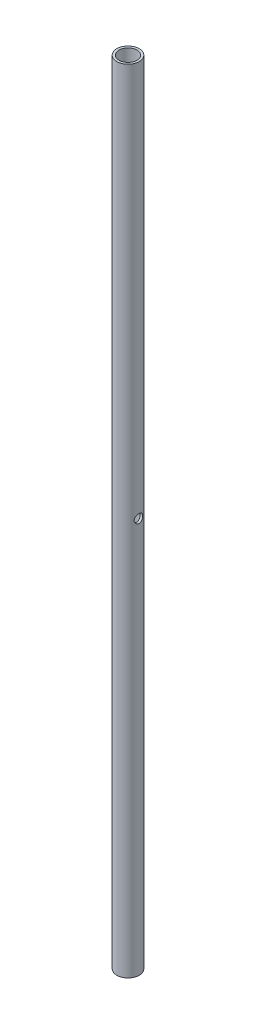
from build123d import *

# Parameters (mm, degrees)
SKETCH1_R               = 16.7005
SKETCH1_R_2             = 13.335
BOSS_EXTRUDE1_DEPTH     = 520.7
SKETCH3_R               = 16.7005
SKETCH3_R_2             = 13.335
BOSS_EXTRUDE2_DEPTH     = 660.4
SKETCH2_R               = 6.35
CUT_EXTRUDE1_DEPTH      = 17.7005
CUT_EXTRUDE1_DEPTH_BACK = 17.7005


with BuildPart() as part:
    # Sketch1 → Boss-Extrude1 (new body)
    with BuildSketch(Plane(origin=(0, 0, 0), x_dir=(1, 0, 0), z_dir=(0, 1, 0))):
        Circle(SKETCH1_R)
        Circle(SKETCH1_R_2, mode=Mode.SUBTRACT)
    extrude(amount=BOSS_EXTRUDE1_DEPTH)

    # Sketch3 → Boss-Extrude2 (add)
    with BuildSketch(Plane.XZ):
        Circle(SKETCH3_R)
        Circle(SKETCH3_R_2, mode=Mode.SUBTRACT)
    extrude(amount=BOSS_EXTRUDE2_DEPTH)

    # Sketch2 → Cut-Extrude1 (cut, two sides)
    with BuildSketch(Plane(origin=(0, 0, 0), x_dir=(0, 0, -1), z_dir=(1, 0, 0))) as cut_extrude1_sk:
        with Locations((0, -69.85)):
            Circle(SKETCH2_R)
    extrude(amount=CUT_EXTRUDE1_DEPTH, mode=Mode.SUBTRACT)
    extrude(cut_extrude1_sk.sketch, amount=-CUT_EXTRUDE1_DEPTH_BACK, mode=Mode.SUBTRACT)


solid = part.part
